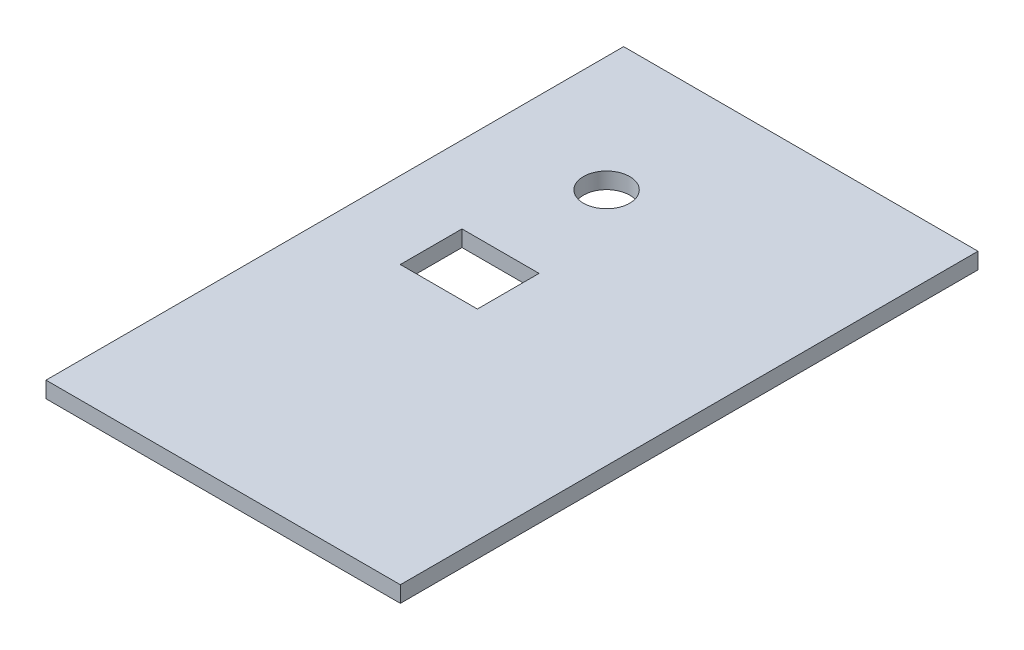
from build123d import *

# Parameters (mm, degrees)
SKETCH1_W           = 23.005
SKETCH1_H           = 37.5
SKETCH1_R           = 1.5025
SKETCH1_W_2         = 5.005
SKETCH1_H_2         = 4.005
BOSS_EXTRUDE1_DEPTH = 1.05


with BuildPart() as part:
    # Sketch1 → Boss-Extrude1 (new body)
    with BuildSketch(Plane(origin=(0, 0, 0), x_dir=(1, 0, 0), z_dir=(0, 1, 0))):
        Rectangle(SKETCH1_W, SKETCH1_H)
        with Locations((-4.0025, 10.14275)):
            Circle(SKETCH1_R, mode=Mode.SUBTRACT)
        with Locations((-4, 1.2525)):
            Rectangle(SKETCH1_W_2, SKETCH1_H_2, mode=Mode.SUBTRACT)
    extrude(amount=BOSS_EXTRUDE1_DEPTH)


solid = part.part
